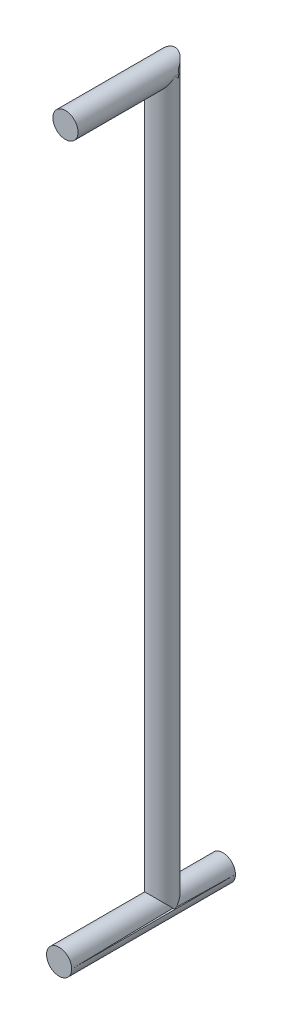
from build123d import *

# Parameters (mm, degrees)
SKETCH1_R                = 1
BOSS_EXTRUDE1_DEPTH      = 59.28
CUT_EXTRUDE1_DEPTH       = 59.28
SKETCH3_R                = 1
BOSS_EXTRUDE2_DEPTH      = 5
BOSS_EXTRUDE2_DEPTH_BACK = 3
BOSS_EXTRUDE3_START      = -2.5
SKETCH4_R                = 1
BOSS_EXTRUDE3_DEPTH      = 5
CUT_EXTRUDE2_DEPTH       = 15
SKETCH6_R                = 1
BOSS_EXTRUDE4_DEPTH      = 13


with BuildPart() as part:
    # Sketch1 → Boss-Extrude1 (new body)
    with BuildSketch(Plane(origin=(0, 0, 0), x_dir=(1, 0, 0), z_dir=(0, 1, 0))):
        with Locations((-15.419703787, 2.701939454)):
            Circle(SKETCH1_R)
    extrude(amount=BOSS_EXTRUDE1_DEPTH)

    # Sketch2 → Cut-Extrude1 (cut)
    with BuildSketch(Plane.XY):
        with BuildLine():
            Line((-16.419703787, 59.28), (-16.419703787, 58.28))
            ThreePointArc((-16.419703787, 58.28), (-16.126810568, 58.987106781), (-15.419703787, 59.28))
            Line((-15.419703787, 59.28), (-16.419703787, 59.28))
        make_face()
        with BuildLine():
            ThreePointArc((-15.419703787, 59.28), (-14.712597006, 58.987106781), (-14.419703787, 58.28))
            Line((-14.419703787, 58.28), (-14.419703787, 59.28))
            Line((-14.419703787, 59.28), (-15.419703787, 59.28))
        make_face()
    extrude(amount=-CUT_EXTRUDE1_DEPTH, mode=Mode.SUBTRACT)

    # Sketch3 → Boss-Extrude2 (add, two sides)
    with BuildSketch(Plane.XY) as boss_extrude2_sk:
        with Locations((-15.419703787, 58.28)):
            Circle(SKETCH3_R)
    extrude(amount=BOSS_EXTRUDE2_DEPTH)
    extrude(boss_extrude2_sk.sketch, amount=-BOSS_EXTRUDE2_DEPTH_BACK)

    # Sketch4 → Boss-Extrude3 (add)
    with BuildSketch(Plane.XY.offset(BOSS_EXTRUDE3_START)):
        with Locations((-15.419703787, 1)):
            Circle(SKETCH4_R)
    extrude(amount=-BOSS_EXTRUDE3_DEPTH)

    # Sketch5 → Cut-Extrude2 (cut)
    with BuildSketch(Plane(origin=(0, 0, -7.5), x_dir=(-1, 0, 0), z_dir=(0, 0, -1))):
        with BuildLine():
            ThreePointArc((15.419703787, 0), (14.712597006, 0.292893219), (14.419703787, 1))
            Line((14.419703787, 1), (14.419703787, 0))
            Line((14.419703787, 0), (15.419703787, 0))
        make_face()
        with BuildLine():
            Line((16.419703787, 0), (16.419703787, 1))
            ThreePointArc((16.419703787, 1), (16.126810568, 0.292893219), (15.419703787, 0))
            Line((15.419703787, 0), (16.419703787, 0))
        make_face()
    extrude(amount=-CUT_EXTRUDE2_DEPTH, mode=Mode.SUBTRACT)

    # Sketch6 → Boss-Extrude4 (add)
    with BuildSketch(Plane(origin=(0, 0, -7.5), x_dir=(-1, 0, 0), z_dir=(0, 0, -1))):
        with Locations((15.419703787, 1)):
            Circle(SKETCH6_R)
    extrude(amount=-BOSS_EXTRUDE4_DEPTH)


solid = part.part
